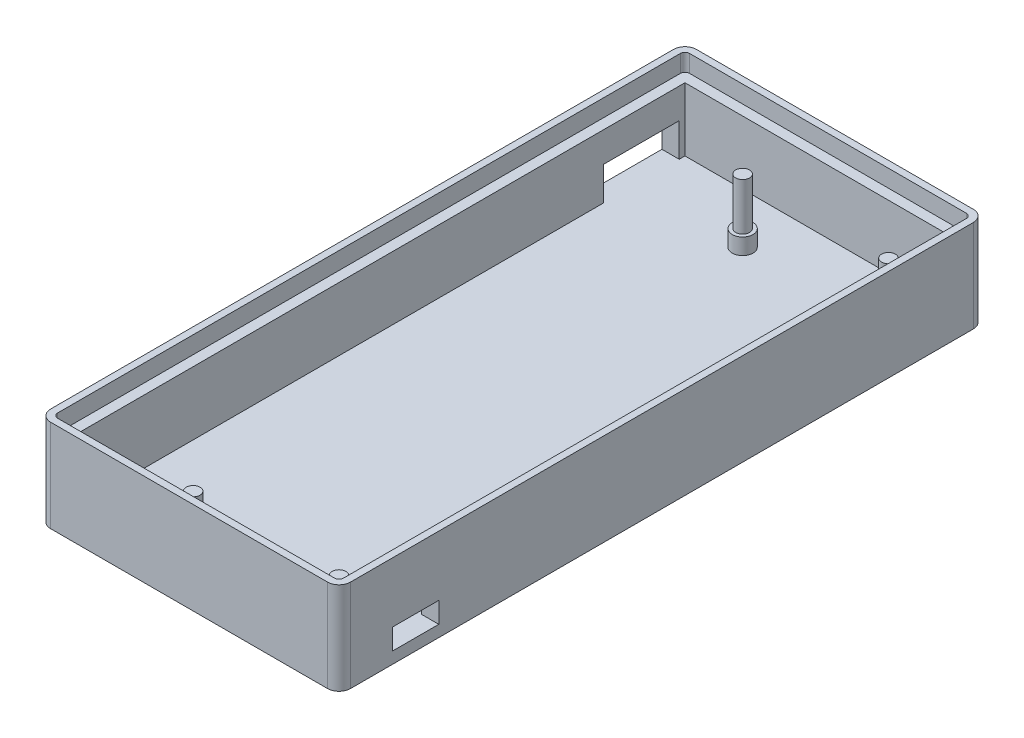
from build123d import *

# Parameters (mm, degrees)
SKETCH1_W           = 50
SKETCH1_H           = 110
BOSS_EXTRUDE1_DEPTH = 2
SKETCH2_W           = 50
SKETCH2_H           = 110
SKETCH2_W_2         = 46
SKETCH2_H_2         = 106
BOSS_EXTRUDE3_DEPTH = 11
SKETCH3_R           = 1.2
BOSS_EXTRUDE4_DEPTH = 11
SKETCH4_W           = 52
SKETCH4_H           = 112
SKETCH4_W_2         = 50
SKETCH4_H_2         = 110
EXTRUDE_THIN1_DEPTH = 13
FILLET2_R           = 2
EXTRUDE_THIN3_DEPTH = 3
SKETCH6_R           = 1.8
BOSS_EXTRUDE5_DEPTH = 2.8
SKETCH8_W           = 8
SKETCH8_H           = 3.6
CUT_EXTRUDE2_DEPTH  = 12.8
SKETCH11_W          = 13.1
SKETCH11_H          = 5.8
CUT_EXTRUDE5_DEPTH  = 3


with BuildPart() as part:
    # Sketch1 → Boss-Extrude1 (new body)
    with BuildSketch(Plane(origin=(0, 0, 0), x_dir=(1, 0, 0), z_dir=(0, 1, 0))):
        with Locations((-52.022587269, -1.919917864)):
            Rectangle(SKETCH1_W, SKETCH1_H)
    extrude(amount=BOSS_EXTRUDE1_DEPTH)

    # Sketch2 → Boss-Extrude3 (add)
    with BuildSketch(Plane(origin=(0, 2, 0), x_dir=(1, 0, 0), z_dir=(0, 1, 0))):
        with Locations((-52.022587269, -1.919917864)):
            Rectangle(SKETCH2_W, SKETCH2_H)
        with Locations((-52.022587269, -1.919917864)):
            Rectangle(SKETCH2_W_2, SKETCH2_H_2, mode=Mode.SUBTRACT)
    extrude(amount=BOSS_EXTRUDE3_DEPTH)

    # Sketch3 → Boss-Extrude4 (add)
    with BuildSketch(Plane(origin=(0, 2, 0), x_dir=(1, 0, 0), z_dir=(0, 1, 0))):
        with Locations((-31.022587269, 42.380082136)):
            Circle(SKETCH3_R)
        with Locations((-31.022587269, -52.919917864)):
            Circle(SKETCH3_R)
        with Locations((-56.322587269, 42.380082136)):
            Circle(SKETCH3_R)
        with Locations((-56.322587269, -52.919917864)):
            Circle(SKETCH3_R)
    extrude(amount=BOSS_EXTRUDE4_DEPTH)

    # Sketch4 → Extrude-Thin1 (add)
    with BuildSketch(Plane(origin=(0, 13, 0), x_dir=(1, 0, 0), z_dir=(0, 1, 0))):
        with Locations((-52.022587269, -1.919917864)):
            Rectangle(SKETCH4_W, SKETCH4_H)
        with Locations((-52.022587269, -1.919917864)):
            Rectangle(SKETCH4_W_2, SKETCH4_H_2, mode=Mode.SUBTRACT)
    extrude(amount=-EXTRUDE_THIN1_DEPTH)

    # Fillet2
    fillet2_edges = [part.edges().sort_by_distance(p)[0] for p in [
        (-26.022587269, 6.5, -54.080082136),
        (-26.022587269, 6.5, 57.919917864),
        (-78.022587269, 6.5, 57.919917864),
        (-78.022587269, 6.5, -54.080082136),
    ]]
    fillet(fillet2_edges, radius=FILLET2_R)

    # Sketch5 → Extrude-Thin3 (add)
    with BuildSketch(Plane(origin=(0, 13, 0), x_dir=(1, 0, 0), z_dir=(0, 1, 0))):
        with BuildLine():
            Line((-28.022587269, 54.080082136), (-76.022587269, 54.080082136))
            ThreePointArc((-76.022587269, 54.080082136), (-77.436800831, 53.494295698), (-78.022587269, 52.080082136))
            Line((-78.022587269, 52.080082136), (-78.022587269, -55.919917864))
            ThreePointArc((-78.022587269, -55.919917864), (-77.436800831, -57.334131427), (-76.022587269, -57.919917864))
            Line((-76.022587269, -57.919917864), (-28.022587269, -57.919917864))
            ThreePointArc((-28.022587269, -57.919917864), (-26.608373707, -57.334131427), (-26.022587269, -55.919917864))
            Line((-26.022587269, -55.919917864), (-26.022587269, 52.080082136))
            ThreePointArc((-26.022587269, 52.080082136), (-26.608373707, 53.494295698), (-28.022587269, 54.080082136))
        make_face()
        with BuildLine():
            Line((-28.022587269, 52.880082136), (-76.022587269, 52.880082136))
            ThreePointArc((-76.022587269, 52.880082136), (-76.588272694, 52.64576756), (-76.822587269, 52.080082136))
            Line((-76.822587269, 52.080082136), (-76.822587269, -55.919917864))
            ThreePointArc((-76.822587269, -55.919917864), (-76.588272694, -56.485603289), (-76.022587269, -56.719917864))
            Line((-76.022587269, -56.719917864), (-28.022587269, -56.719917864))
            ThreePointArc((-28.022587269, -56.719917864), (-27.456901844, -56.485603289), (-27.222587269, -55.919917864))
            Line((-27.222587269, -55.919917864), (-27.222587269, 52.080082136))
            ThreePointArc((-27.222587269, 52.080082136), (-27.456901844, 52.64576756), (-28.022587269, 52.880082136))
        make_face(mode=Mode.SUBTRACT)
    extrude(amount=EXTRUDE_THIN3_DEPTH)

    # Sketch6 → Boss-Extrude5 (add)
    with BuildSketch(Plane(origin=(0, 2, 0), x_dir=(1, 0, 0), z_dir=(0, 1, 0))):
        with Locations((-56.322587269, -52.919917864)):
            Circle(SKETCH6_R)
        with Locations((-31.022587269, -52.919917864)):
            Circle(SKETCH6_R)
        with Locations((-56.322587269, 42.380082136)):
            Circle(SKETCH6_R)
        with Locations((-31.022587269, 42.380082136)):
            Circle(SKETCH6_R)
    extrude(amount=BOSS_EXTRUDE5_DEPTH)

    # Sketch8 → Cut-Extrude2 (cut)
    with BuildSketch(Plane(origin=(-26.022587269, 0, 0), x_dir=(0, 0, -1), z_dir=(1, 0, 0))):
        with Locations((-44.619917864, 3.8)):
            Rectangle(SKETCH8_W, SKETCH8_H)
    extrude(amount=-CUT_EXTRUDE2_DEPTH, mode=Mode.SUBTRACT)

    # Sketch11 → Cut-Extrude5 (cut)
    with BuildSketch(Plane.ZY.offset(78.022587269)):
        with Locations((-43.530082136, 4.9)):
            Rectangle(SKETCH11_W, SKETCH11_H)
    extrude(amount=-CUT_EXTRUDE5_DEPTH, mode=Mode.SUBTRACT)


solid = part.part
